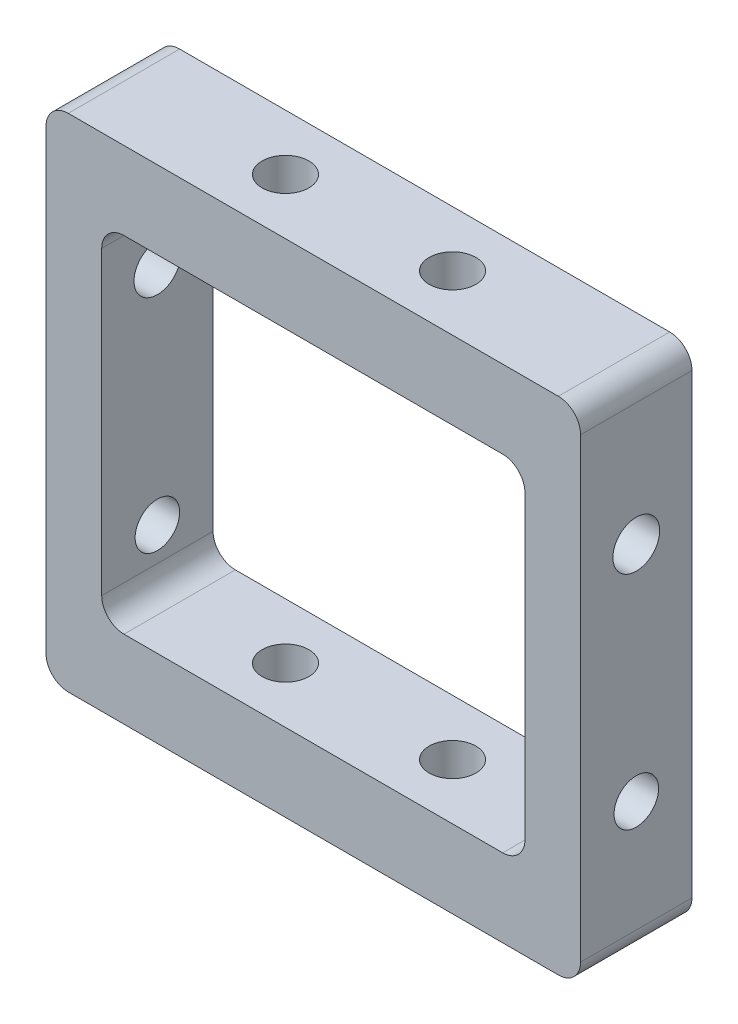
from build123d import *

# Parameters (mm, degrees)
SKETCH_1_W               = 48
SKETCH_1_H               = 45
EXTRUDE_1_DEPTH          = 10
SKETCH_2_R               = 2.5
CUT_EXTRUDE_1_DEPTH      = 1
CUT_EXTRUDE_1_DEPTH_BACK = 46
SKETCH_3_R               = 2
CUT_EXTRUDE_2_DEPTH      = 49
SKETCH_4_R               = 1.75
CUT_EXTRUDE_3_DEPTH      = 1.0000001
CUT_EXTRUDE_3_DEPTH_BACK = 49.0000001
SKETCH_5_W               = 17.7
SKETCH_5_H               = 17
CUT_EXTRUDE_4_DEPTH      = 11
SKETCH_6_W               = 17.7
SKETCH_6_H               = 1.5
SKETCH_6_H_2             = 2.5
CUT_EXTRUDE_5_DEPTH      = 11
SKETCH_8_R               = 2.5
EXTRUDE_2_DEPTH          = 45
SKETCH_10_R              = 1.75
CUT_EXTRUDE_8_DEPTH      = 45
SKETCH_16_W              = 38
SKETCH_16_H              = 37
CUT_EXTRUDE_13_DEPTH     = 11
SKETCH_17_W              = 38
SKETCH_17_H              = 10
SKETCH_17_R              = 1.75
EXTRUDE_4_DEPTH          = 3.5
SKETCH_18_W              = 38
SKETCH_18_H              = 10
SKETCH_18_R              = 1.75
EXTRUDE_5_DEPTH          = 2.5
FILLET_2_R               = 2
HOLE_WIZARD_M5_2_D       = 4.2
HOLE_WIZARD_M5_2_DEPTH   = 45
HOLE_WIZARD_M5_3_D       = 4.2
HOLE_WIZARD_M5_3_DEPTH   = 48
FILLET_3_R               = 2


with BuildPart() as part:
    # 草图1 → 凸台-拉伸1 (new body)
    with BuildSketch(Plane.XY):
        Rectangle(SKETCH_1_W, SKETCH_1_H)
    extrude(amount=EXTRUDE_1_DEPTH)

    # 草图2 → 切除-拉伸1 (cut, two sides)
    with BuildSketch(Plane(origin=(0, 22.5, 0), x_dir=(1, 0, 0), z_dir=(0, 1, 0))) as cut_extrude_1_sk:
        with Locations((10, -5)):
            Circle(SKETCH_2_R)
        with Locations((-10, -5)):
            Circle(SKETCH_2_R)
    extrude(amount=CUT_EXTRUDE_1_DEPTH, mode=Mode.SUBTRACT)
    extrude(cut_extrude_1_sk.sketch, amount=-CUT_EXTRUDE_1_DEPTH_BACK, mode=Mode.SUBTRACT)

    # 草图3 → 切除-拉伸2 (cut, through all)
    with BuildSketch(Plane(origin=(24, 0, 0), x_dir=(0, 0, -1), z_dir=(1, 0, 0))):
        with Locations((-5, -10.5)):
            Circle(SKETCH_3_R)
    extrude(amount=-CUT_EXTRUDE_2_DEPTH, mode=Mode.SUBTRACT)

    # 草图4 → 切除-拉伸3 (cut, two sides)
    with BuildSketch(Plane(origin=(24, 0, 0), x_dir=(0, 0, -1), z_dir=(1, 0, 0))) as cut_extrude_3_sk:
        with Locations((-5, 9.5)):
            Circle(SKETCH_4_R)
    extrude(amount=CUT_EXTRUDE_3_DEPTH, mode=Mode.SUBTRACT)
    extrude(cut_extrude_3_sk.sketch, amount=-CUT_EXTRUDE_3_DEPTH_BACK, mode=Mode.SUBTRACT)

    # 草图5 → 切除-拉伸4 (cut, through all)
    with BuildSketch(Plane.XY.offset(10)):
        with Locations((-10.15, -10.5)):
            Rectangle(SKETCH_5_W, SKETCH_5_H)
        with Locations((10.15, -10.5)):
            Rectangle(SKETCH_5_W, SKETCH_5_H)
        with Locations((-10.15, 9.5)):
            Rectangle(SKETCH_5_W, SKETCH_5_H)
        with Locations((10.15, 9.5)):
            Rectangle(SKETCH_5_W, SKETCH_5_H)
    extrude(amount=-CUT_EXTRUDE_4_DEPTH, mode=Mode.SUBTRACT)

    # 草图6 → 切除-拉伸5 (cut, through all)
    with BuildSketch(Plane.XY.offset(10)):
        with Locations((-10.15, 17.25)):
            Rectangle(SKETCH_6_W, SKETCH_6_H)
        with Locations((10.15, 17.25)):
            Rectangle(SKETCH_6_W, SKETCH_6_H)
        with Locations((-10.15, -0.25)):
            Rectangle(SKETCH_6_W, SKETCH_6_H_2)
        with Locations((10.15, -0.25)):
            Rectangle(SKETCH_6_W, SKETCH_6_H_2)
    extrude(amount=-CUT_EXTRUDE_5_DEPTH, mode=Mode.SUBTRACT)

    # 草图8 → 凸台-拉伸2 (add)
    with BuildSketch(Plane(origin=(0, 22.5, 0), x_dir=(1, 0, 0), z_dir=(0, 1, 0))):
        with Locations((10, -5)):
            Circle(SKETCH_8_R)
        with Locations((-10, -5)):
            Circle(SKETCH_8_R)
    extrude(amount=-EXTRUDE_2_DEPTH)

    # 草图10 → 切除-拉伸8 (cut)
    with BuildSketch(Plane(origin=(0, 22.5, 0), x_dir=(1, 0, 0), z_dir=(0, 1, 0))):
        with Locations((-7.5, -5)):
            Circle(SKETCH_10_R)
        with Locations((7.5, -5)):
            Circle(SKETCH_10_R)
    extrude(amount=-CUT_EXTRUDE_8_DEPTH, mode=Mode.SUBTRACT)

    # 草图16 → 切除-拉伸13 (cut, through all)
    with BuildSketch(Plane.XY.offset(10)):
        with Locations((0, -0.5)):
            Rectangle(SKETCH_16_W, SKETCH_16_H)
    extrude(amount=-CUT_EXTRUDE_13_DEPTH, mode=Mode.SUBTRACT)

    # 草图17 → 凸台-拉伸4 (add)
    with BuildSketch(Plane(origin=(0, -19, 0), x_dir=(1, 0, 0), z_dir=(0, 1, 0))):
        with Locations((0, -5)):
            Rectangle(SKETCH_17_W, SKETCH_17_H)
        with Locations((7.5, -5)):
            Circle(SKETCH_17_R, mode=Mode.SUBTRACT)
        with Locations((-7.5, -5)):
            Circle(SKETCH_17_R, mode=Mode.SUBTRACT)
    extrude(amount=EXTRUDE_4_DEPTH)

    # 草图18 → 凸台-拉伸5 (add)
    with BuildSketch(Plane.XZ.offset(-18)):
        with Locations((0, 5)):
            Rectangle(SKETCH_18_W, SKETCH_18_H)
        with Locations((-7.5, 5)):
            Circle(SKETCH_18_R, mode=Mode.SUBTRACT)
        with Locations((7.5, 5)):
            Circle(SKETCH_18_R, mode=Mode.SUBTRACT)
    extrude(amount=EXTRUDE_5_DEPTH)

    # 圆角2
    fillet_2_edges = [part.edges().sort_by_distance(p)[0] for p in [
        (-19, -15.5, 5),
        (19, -15.5, 5),
        (19, 15.5, 5),
        (-19, 15.5, 5),
    ]]
    fillet(fillet_2_edges, radius=FILLET_2_R)

    # M5 螺纹孔的螺纹孔钻头2
    with Locations(Plane(origin=(0, 22.5, 0), x_dir=(1, 0, 0), z_dir=(0, 1, 0))):
        with Locations((-7.5, -5), (7.5, -5)):
            Hole(HOLE_WIZARD_M5_2_D / 2, depth=HOLE_WIZARD_M5_2_DEPTH)

    # M5 螺纹孔的螺纹孔钻头3
    with Locations(Plane(origin=(24, 0, 0), x_dir=(0, 0, -1), z_dir=(1, 0, 0))):
        with Locations((-5, 9.5)):
            Hole(HOLE_WIZARD_M5_3_D / 2, depth=HOLE_WIZARD_M5_3_DEPTH)

    # 圆角3
    fillet_3_edges = [part.edges().sort_by_distance(p)[0] for p in [
        (24, -22.5, 5),
        (-24, -22.5, 5),
        (-24, 22.5, 5),
        (24, 22.5, 5),
    ]]
    fillet(fillet_3_edges, radius=FILLET_3_R)


solid = part.part
